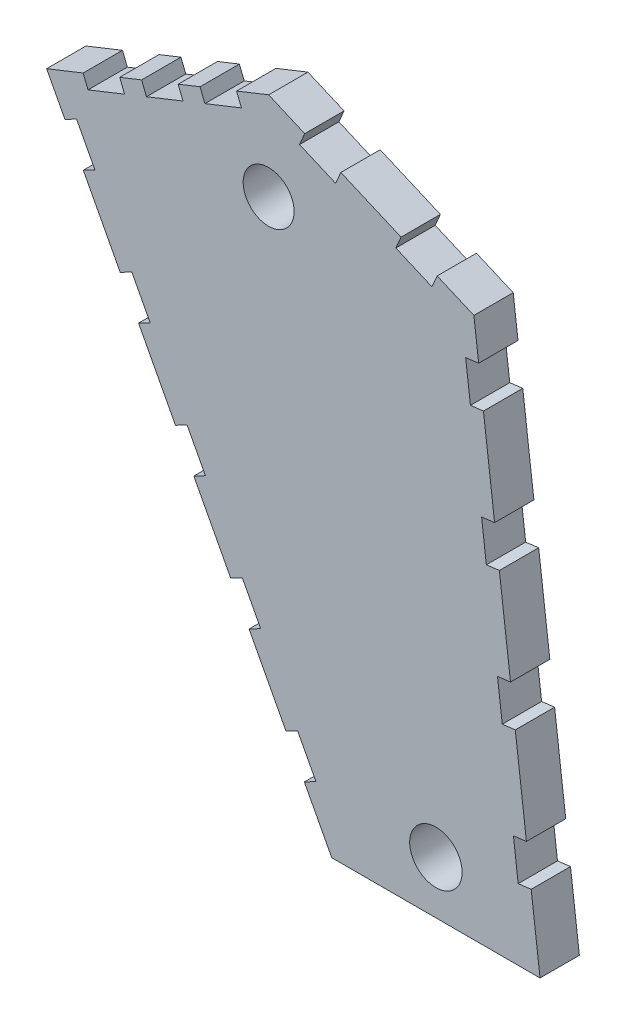
from build123d import *

# Parameters (mm, degrees)
SKETCH1_R           = 6.171386398
BOSS_EXTRUDE1_DEPTH = 9.525
CUT_EXTRUDE1_DEPTH  = 9.525
CUT_EXTRUDE2_DEPTH  = 9.525
CUT_EXTRUDE3_DEPTH  = 9.525
SKETCH3_R           = 6.35
CUT_EXTRUDE4_DEPTH  = 9.525


with BuildPart() as part:
    # Sketch1 → Boss-Extrude1 (new body)
    with BuildSketch(Plane.XY):
        Polygon((0, 0), (53.773244147, 21.40735786), (103.498996656, 0), (119.524414716, -130.99264214), (69.064214047, -130.99264214), align=None)
        with Locations((53.773244147, 0)):
            Circle(SKETCH1_R, mode=Mode.SUBTRACT)
    extrude(amount=BOSS_EXTRUDE1_DEPTH)

    # Sketch2 → Cut-Extrude1 (cut)
    with BuildSketch(Plane.XY.offset(9.525)):
        Polygon((17.699027193, 7.046058219), (8.849513596, 3.523029109), (10.023856633, 0.573191244), (18.873370229, 4.096220353), align=None)
        Polygon((31.858248947, 12.682904794), (23.008735351, 9.159875685), (24.183078387, 6.210037819), (33.032591984, 9.733066929), align=None)
        Polygon((46.017470702, 18.319751369), (37.167957105, 14.79672226), (38.342300142, 11.846884394), (47.191813738, 15.369913504), align=None)
    extrude(amount=-CUT_EXTRUDE1_DEPTH, mode=Mode.SUBTRACT)

    # Sketch2_3 → Cut-Extrude2 (cut)
    with BuildSketch(Plane.XY.offset(9.525)):
        Polygon((7.250861941, -6.944872289), (4.44231406, -8.425643642), (8.884628121, -16.851287285), (11.693176002, -15.370515931), align=None)
        Polygon((20.637034977, -32.334145131), (17.828487096, -33.814916485), (22.270801156, -42.240560127), (25.079349037, -40.759788774), align=None)
        Polygon((34.023208012, -57.723417974), (31.214660132, -59.204189327), (35.656974192, -67.629832969), (38.465522073, -66.149061616), align=None)
        Polygon((47.409381048, -83.112690816), (44.600833167, -84.593462169), (49.043147228, -93.019105812), (51.851695108, -91.538334458), align=None)
        Polygon((60.795554083, -108.501963658), (57.987006203, -109.982735012), (62.429320263, -118.408378654), (65.237868144, -116.927607301), align=None)
    extrude(amount=-CUT_EXTRUDE2_DEPTH, mode=Mode.SUBTRACT)

    # Sketch2_4 → Cut-Extrude3 (cut)
    with BuildSketch(Plane.XY.offset(9.525)):
        Polygon((71.270661843, 13.874571258), (62.521952995, 17.640964559), (61.266488562, 14.724728276), (70.015197409, 10.958334976), align=None)
        Polygon((94.600552104, 3.83085579), (85.851843256, 7.597249091), (84.596378823, 4.681012808), (93.34508767, 0.914619507), align=None)
        Polygon((105.812294522, -18.909023057), (104.655645589, -9.454511529), (101.504141746, -9.840061173), (102.660790679, -19.294572702), align=None)
        Polygon((114.227280012, -113.839687988), (117.378783855, -113.454138344), (116.222134922, -103.999626815), (113.070631079, -104.385176459), align=None)
        Polygon((109.667790966, -50.424061486), (108.511142033, -40.969549957), (105.35963819, -41.355099602), (106.516287124, -50.80961113), align=None)
        Polygon((110.371783568, -82.324649559), (113.523287411, -81.939099915), (112.366638477, -72.484588386), (109.215134635, -72.870138031), align=None)
    extrude(amount=-CUT_EXTRUDE3_DEPTH, mode=Mode.SUBTRACT)

    # Sketch3 → Cut-Extrude4 (cut)
    with BuildSketch(Plane.XY.offset(9.525)):
        with Locations((94.294314381, -118.29264214)):
            Circle(SKETCH3_R)
    extrude(amount=-CUT_EXTRUDE4_DEPTH, mode=Mode.SUBTRACT)


solid = part.part
